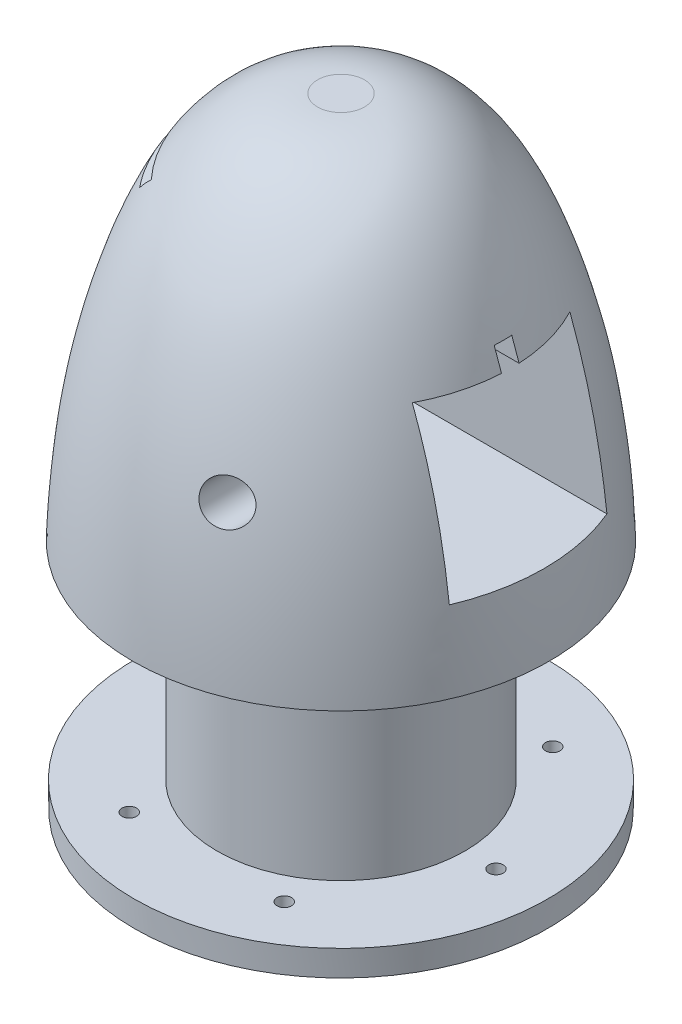
from build123d import *

# Parameters (mm, degrees)
CUT_EXTRUDE1_DEPTH      = 52.443023194
CUT_EXTRUDE1_DEPTH_BACK = 12.7
SKETCH5_R               = 24.444582539
CUT_EXTRUDE2_DEPTH      = 66.04
SKETCH10_R              = 3.175
CUT_EXTRUDE3_DEPTH      = 52.443023194
CUT_EXTRUDE3_DEPTH_BACK = 52.443023194
SKETCH12_R              = 5.08
CUT_EXTRUDE4_DEPTH      = 43.688
CUT_EXTRUDE4_DEPTH_BACK = 0.508
SKETCH13_R              = 5.08
CUT_EXTRUDE5_DEPTH      = 43.688
SKETCH19_W              = 74.622524606
SKETCH19_H              = 50.8
SKETCH16_R              = 1.778
CUT_EXTRUDE6_DEPTH      = 7.62
CUT_EXTRUDE7_DEPTH      = 19.05


with BuildPart() as part:
    # Sketch3 → Revolve2 (revolve)
    with BuildSketch(Plane(origin=(0, 0, 0), x_dir=(0, 0, -1), z_dir=(1, 0, 0))):
        with BuildLine():
            Line((0, 0), (0, 152.4))
            Line((0, 152.4), (5.775087988, 152.4))
            add(Edge.make_bspline(
                [(5.775087988, 152.4), (26.104606075, 152.101942681), (56.331539835, 91.459760386), (51.027706874, 40.286381735), (50.8, 0)],
                knots=[0, 0, 0, 0, 0.330383286, 1, 1, 1, 1], degree=3))
            Line((50.8, 0), (0, 0))
        make_face()
    revolve(axis=Axis((0, 0, 0), (0, 1, 0)))

    # Sketch4 → Cut-Extrude1 (cut, two sides)
    with BuildSketch(Plane(origin=(0, 0, 0), x_dir=(0, 0, -1), z_dir=(1, 0, 0))) as cut_extrude1_sk:
        Polygon((-19.3675, 114.681), (-2.159, 114.681), (-2.159, 119.761), (2.159, 119.761), (2.159, 114.681), (19.3675, 114.681), (19.3675, 76.2), (-19.3675, 76.2), align=None)
    extrude(amount=CUT_EXTRUDE1_DEPTH, mode=Mode.SUBTRACT)
    extrude(cut_extrude1_sk.sketch, amount=-CUT_EXTRUDE1_DEPTH_BACK, mode=Mode.SUBTRACT)

    # Sketch5 → Cut-Extrude2 (cut)
    with BuildSketch(Plane(origin=(0, 0, 0), x_dir=(0, 0, -1), z_dir=(1, 0, 0))):
        with Locations((0, 95.4405)):
            Circle(SKETCH5_R)
    extrude(amount=-CUT_EXTRUDE2_DEPTH, mode=Mode.SUBTRACT)

    # Sketch10 → Cut-Extrude3 (cut, two sides)
    with BuildSketch(Plane.XY) as cut_extrude3_sk:
        with Locations((15.896399951, 95.3)):
            Circle(SKETCH10_R)
    extrude(amount=CUT_EXTRUDE3_DEPTH, mode=Mode.SUBTRACT)
    extrude(cut_extrude3_sk.sketch, amount=-CUT_EXTRUDE3_DEPTH_BACK, mode=Mode.SUBTRACT)

    # Sketch12 → Cut-Extrude4 (cut, two sides)
    with BuildSketch(Plane.XY.offset(22.86)) as cut_extrude4_sk:
        with Locations((15.896399951, 95.3)):
            Circle(SKETCH12_R)
    extrude(amount=CUT_EXTRUDE4_DEPTH, mode=Mode.SUBTRACT)
    extrude(cut_extrude4_sk.sketch, amount=-CUT_EXTRUDE4_DEPTH_BACK, mode=Mode.SUBTRACT)

    # Sketch13 → Cut-Extrude5 (cut)
    with BuildSketch(Plane.XY.offset(-22.86)):
        with Locations((15.896399951, 95.3)):
            Circle(SKETCH13_R)
    extrude(amount=-CUT_EXTRUDE5_DEPTH, mode=Mode.SUBTRACT)

    # Sketch19 → Cut-Revolve1 (revolve, cut)
    with BuildSketch(Plane.XY):
        with Locations((67.791262303, 31.75)):
            Rectangle(SKETCH19_W, SKETCH19_H)
    revolve(axis=Axis((0, 0, 0), (0, 1, 0)), mode=Mode.SUBTRACT)

    # Sketch16 → Cut-Extrude6 (cut)
    with BuildSketch(Plane.XZ):
        with Locations((38.1, 0)):
            Circle(SKETCH16_R)
        with Locations((19.05, -32.995567884)):
            Circle(SKETCH16_R)
        with Locations((-19.05, -32.995567884)):
            Circle(SKETCH16_R)
        with Locations((-38.1, 0)):
            Circle(SKETCH16_R)
        with Locations((-19.05, 32.995567884)):
            Circle(SKETCH16_R)
        with Locations((19.05, 32.995567884)):
            Circle(SKETCH16_R)
    extrude(amount=-CUT_EXTRUDE6_DEPTH, mode=Mode.SUBTRACT)

    # Sketch20 → Cut-Extrude7 (cut)
    with BuildSketch(Plane.ZY.offset(35.56)):
        Polygon((23.022216919, 130.648515898), (1.796344675, 133.35), (-1.796344675, 133.35), (-23.022216919, 130.648515898), (-23.681538514, 134.405336053), (-2.037826091, 137.16), (2.037826091, 137.16), (23.681538514, 134.405336053), align=None)
    extrude(amount=-CUT_EXTRUDE7_DEPTH, mode=Mode.SUBTRACT)


solid = part.part
